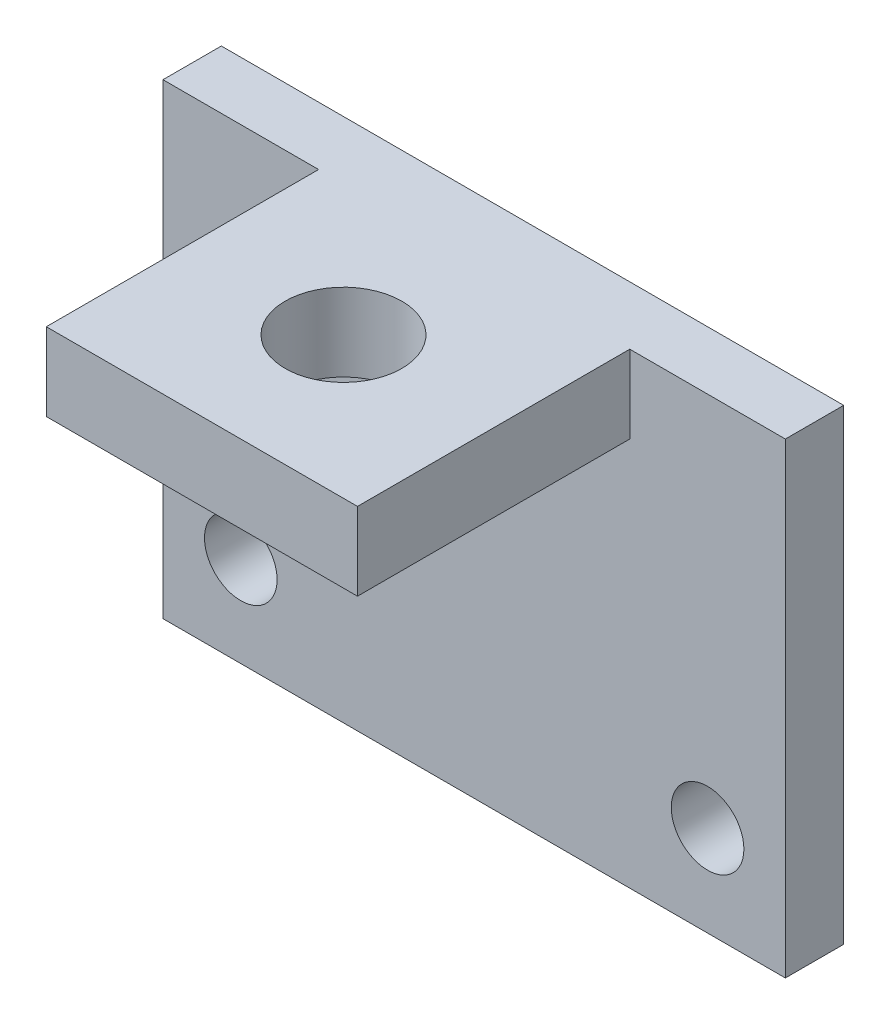
from build123d import *

# Parameters (mm, degrees)
SKETCH_2_W          = 16
SKETCH_2_H          = 12
SKETCH_2_R          = 0.933622945
EXTRUDE_1_DEPTH     = 1.5
SKETCH_3_W          = 8
SKETCH_3_H          = 2
EXTRUDE_2_DEPTH     = 7
SKETCH_4_R          = 1.5
CUT_EXTRUDE_1_DEPTH = 3


with BuildPart() as part:
    # 草图2 → 凸台-拉伸1 (new body)
    with BuildSketch(Plane.XY):
        with Locations((8, 6)):
            Rectangle(SKETCH_2_W, SKETCH_2_H)
        with Locations((2, 2.334057363)):
            Circle(SKETCH_2_R, mode=Mode.SUBTRACT)
        with Locations((14, 2.334057363)):
            Circle(SKETCH_2_R, mode=Mode.SUBTRACT)
    extrude(amount=EXTRUDE_1_DEPTH)

    # 草图3 → 凸台-拉伸2 (add)
    with BuildSketch(Plane.XY.offset(1.5)):
        with Locations((8, 11)):
            Rectangle(SKETCH_3_W, SKETCH_3_H)
    extrude(amount=EXTRUDE_2_DEPTH)

    # 草图4 → 切除-拉伸1 (cut)
    with BuildSketch(Plane.XZ.offset(-10)):
        with Locations((8, 4.86)):
            Circle(SKETCH_4_R)
    extrude(amount=-CUT_EXTRUDE_1_DEPTH, mode=Mode.SUBTRACT)


solid = part.part
